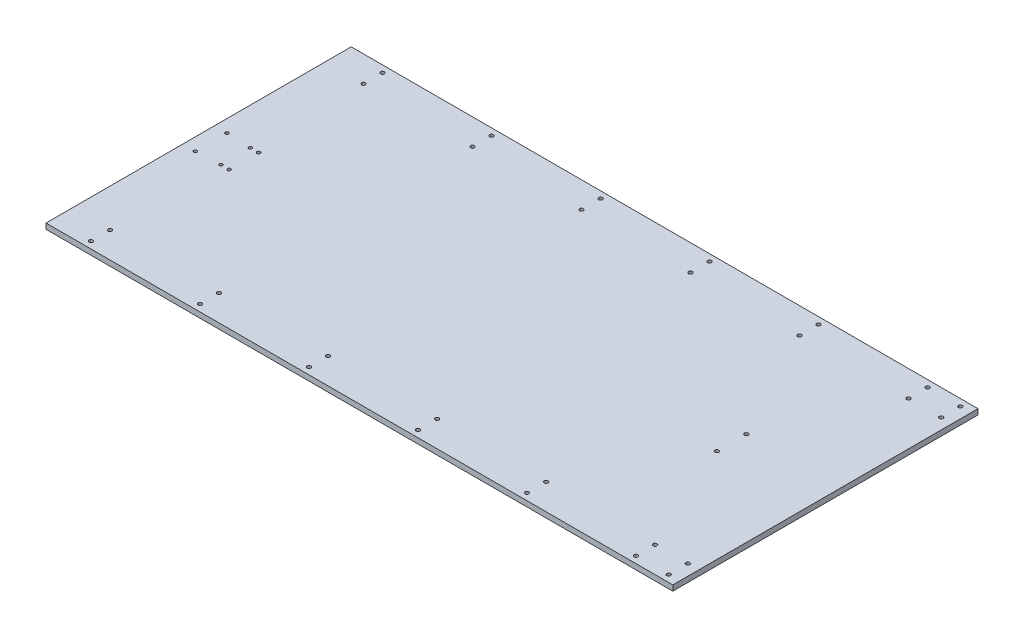
from build123d import *

# Parameters (mm, degrees)
SKETCH_1_W      = 1150
SKETCH_1_H      = 560
SKETCH_1_R      = 3
SKETCH_1_R_2    = 3.5
EXTRUDE_1_DEPTH = 10


with BuildPart() as part:
    # Эскиз1 → Бобышка-Вытянуть1 (new body)
    with BuildSketch(Plane(origin=(0, 0, 0), x_dir=(1, 0, 0), z_dir=(0, 1, 0))):
        with Locations((298.202614379, 6.290849673)):
            Rectangle(SKETCH_1_W, SKETCH_1_H)
        with Locations((-253.797385621, 35.290849673)):
            Circle(SKETCH_1_R, mode=Mode.SUBTRACT)
        with Locations((-208.797385621, 33.290849673)):
            Circle(SKETCH_1_R, mode=Mode.SUBTRACT)
        with Locations((-193.797385621, 33.290849673)):
            Circle(SKETCH_1_R, mode=Mode.SUBTRACT)
        with Locations((-206.797385621, 273.790849673)):
            Circle(SKETCH_1_R_2, mode=Mode.SUBTRACT)
        with Locations((-6.797385621, 273.790849673)):
            Circle(SKETCH_1_R_2, mode=Mode.SUBTRACT)
        with Locations((193.202614379, 273.790849673)):
            Circle(SKETCH_1_R_2, mode=Mode.SUBTRACT)
        with Locations((393.202614379, 273.790849673)):
            Circle(SKETCH_1_R_2, mode=Mode.SUBTRACT)
        with Locations((593.202614379, 273.790849673)):
            Circle(SKETCH_1_R_2, mode=Mode.SUBTRACT)
        with Locations((593.202614379, 238.790849673)):
            Circle(SKETCH_1_R_2, mode=Mode.SUBTRACT)
        with Locations((393.202614379, 238.790849673)):
            Circle(SKETCH_1_R_2, mode=Mode.SUBTRACT)
        with Locations((193.202614379, 238.790849673)):
            Circle(SKETCH_1_R_2, mode=Mode.SUBTRACT)
        with Locations((-6.797385621, 238.790849673)):
            Circle(SKETCH_1_R_2, mode=Mode.SUBTRACT)
        with Locations((-206.797385621, 238.790849673)):
            Circle(SKETCH_1_R_2, mode=Mode.SUBTRACT)
        with Locations((593.202614379, -226.209150327)):
            Circle(SKETCH_1_R_2, mode=Mode.SUBTRACT)
        with Locations((593.202614379, -261.209150327)):
            Circle(SKETCH_1_R_2, mode=Mode.SUBTRACT)
        with Locations((393.202614379, -226.209150327)):
            Circle(SKETCH_1_R_2, mode=Mode.SUBTRACT)
        with Locations((393.202614379, -261.209150327)):
            Circle(SKETCH_1_R_2, mode=Mode.SUBTRACT)
        with Locations((193.202614379, -226.209150327)):
            Circle(SKETCH_1_R_2, mode=Mode.SUBTRACT)
        with Locations((193.202614379, -261.209150327)):
            Circle(SKETCH_1_R_2, mode=Mode.SUBTRACT)
        with Locations((-6.797385621, -226.209150327)):
            Circle(SKETCH_1_R_2, mode=Mode.SUBTRACT)
        with Locations((-6.797385621, -261.209150327)):
            Circle(SKETCH_1_R_2, mode=Mode.SUBTRACT)
        with Locations((-206.797385621, -226.209150327)):
            Circle(SKETCH_1_R_2, mode=Mode.SUBTRACT)
        with Locations((-206.797385621, -261.209150327)):
            Circle(SKETCH_1_R_2, mode=Mode.SUBTRACT)
        with Locations((701.202614379, 33.290849673)):
            Circle(SKETCH_1_R_2, mode=Mode.SUBTRACT)
        with Locations((701.202614379, -20.709150327)):
            Circle(SKETCH_1_R_2, mode=Mode.SUBTRACT)
        with Locations((-193.797385621, -20.709150327)):
            Circle(SKETCH_1_R, mode=Mode.SUBTRACT)
        with Locations((-208.797385621, -20.709150327)):
            Circle(SKETCH_1_R, mode=Mode.SUBTRACT)
        with Locations((-253.797385621, -22.709150327)):
            Circle(SKETCH_1_R, mode=Mode.SUBTRACT)
        with Locations((793.202614379, 273.790849673)):
            Circle(SKETCH_1_R_2, mode=Mode.SUBTRACT)
        with Locations((793.202614379, 238.790849673)):
            Circle(SKETCH_1_R_2, mode=Mode.SUBTRACT)
        with Locations((793.202614379, -226.209150327)):
            Circle(SKETCH_1_R_2, mode=Mode.SUBTRACT)
        with Locations((793.202614379, -261.209150327)):
            Circle(SKETCH_1_R_2, mode=Mode.SUBTRACT)
        with Locations((853.202614379, 273.790849673)):
            Circle(SKETCH_1_R_2, mode=Mode.SUBTRACT)
        with Locations((853.202614379, 238.790849673)):
            Circle(SKETCH_1_R_2, mode=Mode.SUBTRACT)
        with Locations((853.202614379, -226.209150327)):
            Circle(SKETCH_1_R_2, mode=Mode.SUBTRACT)
        with Locations((853.202614379, -261.209150327)):
            Circle(SKETCH_1_R_2, mode=Mode.SUBTRACT)
    extrude(amount=EXTRUDE_1_DEPTH)


solid = part.part
